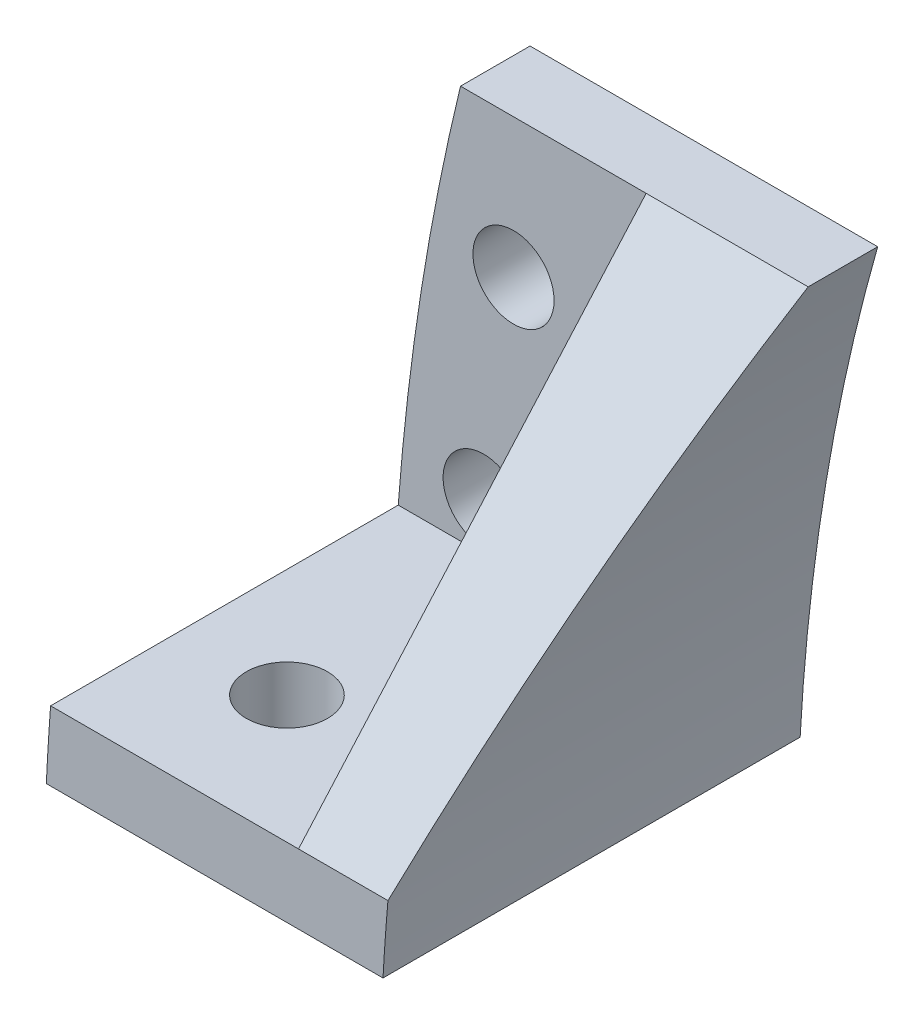
from build123d import *

# Parameters (mm, degrees)
SKETCH1_R                = 1.75
BOSS_EXTRUDE1_DEPTH      = 3
BOSS_EXTRUDE2_DEPTH      = 15
BOSS_EXTRUDE3_REACH      = 34.671
BOSS_EXTRUDE3_END_RADIUS = 91.49157749
SKETCH4_R                = 1.75
CUT_EXTRUDE1_DEPTH       = 31.604747935


with BuildPart() as part:
    # Sketch1 → Boss-Extrude1 (new body)
    with BuildSketch(Plane.XY):
        with BuildLine():
            Line((0.117990197, 5), (14.645149272, 5))
            ThreePointArc((14.645149272, 5), (15.76191903, 15.092961754), (17.99029172, 25))
            Line((17.99029172, 25), (2.99029172, 25))
            ThreePointArc((2.99029172, 25), (1.076516113, 15.068594129), (0.117990197, 5))
        make_face()
        with Locations((3.988971184, 10)):
            Circle(SKETCH1_R, mode=Mode.SUBTRACT)
        with Locations((5.276368215, 19)):
            Circle(SKETCH1_R, mode=Mode.SUBTRACT)
    extrude(amount=BOSS_EXTRUDE1_DEPTH)

    # Sketch2 → Boss-Extrude2 (add)
    with BuildSketch(Plane.XY.offset(3)):
        with BuildLine():
            Line((0.117990197, 5), (14.645149272, 5))
            ThreePointArc((14.645149272, 5), (14.739672725, 6.500878193), (14.858852588, 8))
            Line((14.858852588, 8), (0.302317906, 8))
            ThreePointArc((0.302317906, 8), (0.199520295, 6.500653365), (0.117990197, 5))
        make_face()
    extrude(amount=BOSS_EXTRUDE2_DEPTH)

    # Boss-Extrude3: up to this cylinder (the profile starts outside it)
    boss_extrude3_end = Plane(origin=(106, 0, 8), z_dir=(0, 0, -1)) * Cylinder(BOSS_EXTRUDE3_END_RADIUS, 253.32515498, mode=Mode.PRIVATE)
    # Sketch3 → Boss-Extrude3 (add, up to the surface)
    with BuildSketch(Plane(origin=(11, 0, 0), x_dir=(0, 0, -1), z_dir=(1, 0, 0)), mode=Mode.PRIVATE) as boss_extrude3_sk1:
        Polygon((-18, 8), (-3, 25), (-3, 8), align=None)
    boss_extrude3_tool1 = extrude(boss_extrude3_sk1.sketch, amount=BOSS_EXTRUDE3_REACH, mode=Mode.PRIVATE) - boss_extrude3_end
    add(boss_extrude3_tool1.solids().sort_by_distance((11, 13.666667, 8))[0])

    # Sketch4 → Cut-Extrude1 (cut, through all)
    with BuildSketch(Plane(origin=(0, 8, 0), x_dir=(1, 0, 0), z_dir=(0, 1, 0))):
        with Locations(Location((5, -12.5, 0), (0, 0, 270))):
            Circle(SKETCH4_R)
    extrude(amount=-CUT_EXTRUDE1_DEPTH, mode=Mode.SUBTRACT)


solid = part.part
